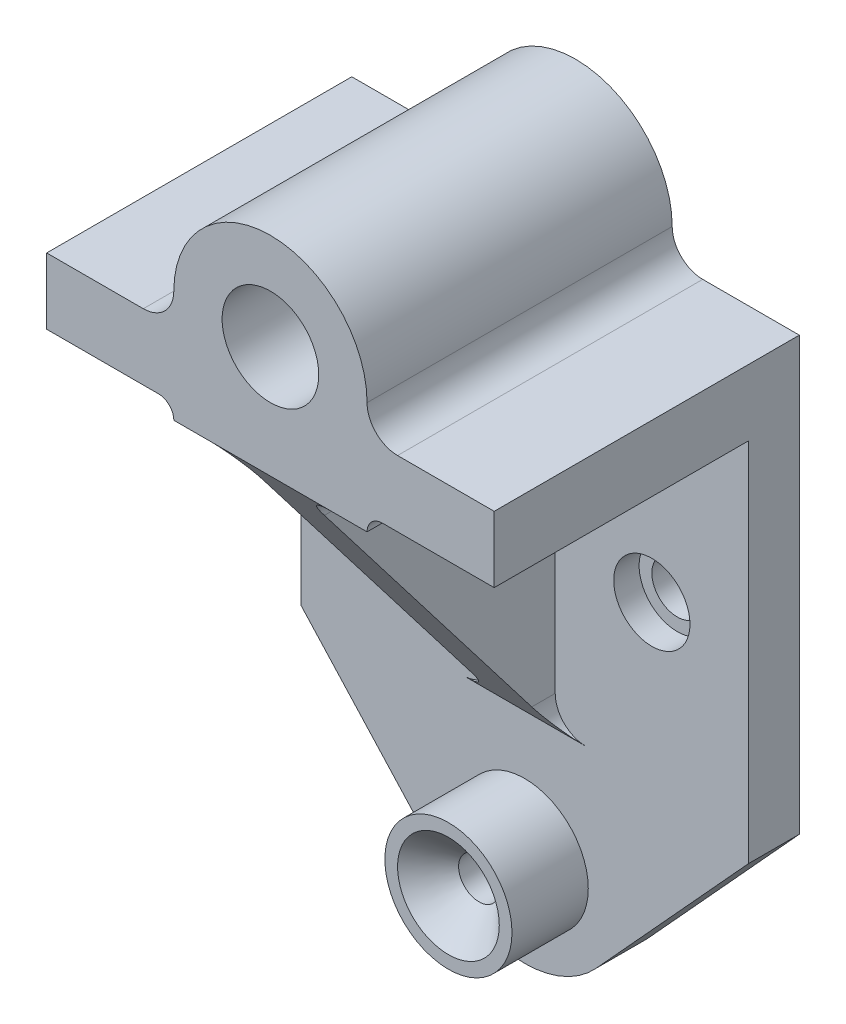
from build123d import *

# Parameters (mm, degrees)
BOSS_EXTRUDE6_DEPTH                          = 60
CUT_EXTRUDE3_DEPTH                           = 150.786514747
CUT_EXTRUDE3_DEPTH_BACK                      = 50
BOSS_EXTRUDE9_DEPTH                          = 50
CUT_EXTRUDE7_DEPTH                           = 25
CBORE_FOR_M8_HEX_HEAD_CAP_SCREW3_D           = 10
CBORE_FOR_M8_HEX_HEAD_CAP_SCREW3_DEPTH       = 10
CBORE_FOR_M8_HEX_HEAD_CAP_SCREW3_CBORE_D     = 15
CBORE_FOR_M8_HEX_HEAD_CAP_SCREW3_CBORE_DEPTH = 5
CBORE_FOR_M8_HEX_HEAD_CAP_SCREW3_TIP         = 3.004303095
CUT_EXTRUDE8_DEPTH                           = 60
SKETCH29_R                                   = 12.5
BOSS_EXTRUDE10_DEPTH                         = 15
BOSS_EXTRUDE11_START                         = -15
SKETCH2_10_R                                 = 12.5
BOSS_EXTRUDE11_DEPTH                         = 15
BOSS_EXTRUDE8_DEPTH                          = 50
CUT_EXTRUDE5_DEPTH                           = 25


with BuildPart() as part:
    # Sketch2 → Boss-Extrude6 (new body)
    with BuildSketch(Plane.XY):
        with BuildLine():
            Line((44, 20), (14.028925254, -12.813635558))
            ThreePointArc((14.028925254, -12.813635558), (0, -19), (-14.028925254, -12.813635558))
            Line((-14.028925254, -12.813635558), (-44, 20))
            Line((-44, 20), (-44, 105))
            Line((-44, 105), (-25, 105))
            ThreePointArc((-25, 105), (-20.757359313, 106.757359313), (-19, 111))
            ThreePointArc((-19, 111), (0, 130), (19, 111))
            ThreePointArc((19, 111), (20.757359313, 106.757359313), (25, 105))
            Line((25, 105), (44, 105))
            Line((44, 105), (44, 20))
        make_face()
    extrude(amount=BOSS_EXTRUDE6_DEPTH)

    # Sketch5 → Cut-Extrude3 (cut, two sides: drawn at the far end of the back side and taken through both)
    with BuildSketch(Plane.XY.offset(60).offset(-CUT_EXTRUDE3_DEPTH_BACK)):
        with BuildLine():
            Line((14.028925254, -12.813635558), (44, 20))
            Line((44, 20), (44, 92))
            Line((44, 92), (22, 92))
            ThreePointArc((22, 92), (19.878679656, 91.121320344), (19, 89))
            Line((19, 89), (-19, 89))
            ThreePointArc((-19, 89), (-19.878679656, 91.121320344), (-22, 92))
            Line((-22, 92), (-44, 92))
            Line((-44, 92), (-44, 20))
            Line((-44, 20), (-14.028925254, -12.813635558))
            ThreePointArc((-14.028925254, -12.813635558), (0, -19), (14.028925254, -12.813635558))
        make_face()
    extrude(amount=CUT_EXTRUDE3_DEPTH + CUT_EXTRUDE3_DEPTH_BACK, mode=Mode.SUBTRACT)

    # Sketch5_11 → Boss-Extrude9 (add)
    with BuildSketch(Plane.XY.offset(60)):
        with BuildLine():
            ThreePointArc((6, 83), (7.757359313, 87.242640687), (12, 89))
            Line((12, 89), (-12, 89))
            ThreePointArc((-12, 89), (-7.757359313, 87.242640687), (-6, 83))
            Line((-6, 83), (-6, 30))
            ThreePointArc((-6, 30), (-7.757359313, 25.757359313), (-12, 24))
            Line((-12, 24), (-9.5, 24))
            Line((-9.5, 24), (9.5, 24))
            Line((9.5, 24), (12, 24))
            ThreePointArc((12, 24), (7.757359313, 25.757359313), (6, 30))
            Line((6, 30), (6, 83))
        make_face()
    extrude(amount=-BOSS_EXTRUDE9_DEPTH)

    # Sketch25 → Cut-Extrude7 (cut, symmetric)
    with BuildSketch(Plane(origin=(6, 0, 0), x_dir=(0, 0, -1), z_dir=(1, 0, 0))):
        Polygon((-60, 89), (-10, 24), (-60, 24), (-60, 30), (-60, 83), align=None)
    extrude(amount=CUT_EXTRUDE7_DEPTH, both=True, mode=Mode.SUBTRACT)

    # CBORE for M8 Hex Head Cap Screw3
    with Locations(Plane(origin=(-25, 55, 10), x_dir=(1, 0, 0), z_dir=(0, 0, 1))):
        with Locations((0, 0), (50, 0)):
            CounterBoreHole(CBORE_FOR_M8_HEX_HEAD_CAP_SCREW3_D / 2, CBORE_FOR_M8_HEX_HEAD_CAP_SCREW3_CBORE_D / 2, CBORE_FOR_M8_HEX_HEAD_CAP_SCREW3_CBORE_DEPTH, depth=CBORE_FOR_M8_HEX_HEAD_CAP_SCREW3_DEPTH)
            with Locations((0, 0, -(CBORE_FOR_M8_HEX_HEAD_CAP_SCREW3_DEPTH + CBORE_FOR_M8_HEX_HEAD_CAP_SCREW3_TIP / 2))):  # 118° drill point
                Cone(0, CBORE_FOR_M8_HEX_HEAD_CAP_SCREW3_D / 2, CBORE_FOR_M8_HEX_HEAD_CAP_SCREW3_TIP, mode=Mode.SUBTRACT)

    # Sketch28 → Cut-Extrude8 (cut)
    with BuildSketch(Plane.XY.offset(60)):
        with BuildLine():
            ThreePointArc((0, 101.5), (9.5, 111), (0, 120.5))
            ThreePointArc((0, 120.5), (-9.5, 111), (0, 101.5))
        make_face()
    extrude(amount=-CUT_EXTRUDE8_DEPTH, mode=Mode.SUBTRACT)

    # Sketch29 → Boss-Extrude10 (add)
    with BuildSketch(Plane.XY.offset(10)):
        Circle(SKETCH29_R)
    extrude(amount=BOSS_EXTRUDE10_DEPTH)

    # Sketch2_10 → Boss-Extrude11 (add)
    with BuildSketch(Plane.XY.offset(BOSS_EXTRUDE11_START)):
        Circle(SKETCH2_10_R)
    extrude(amount=BOSS_EXTRUDE11_DEPTH)

    # Sketch5_9 → Boss-Extrude8 (add)
    with BuildSketch(Plane.XY.offset(60)):
        with BuildLine():
            ThreePointArc((6, 83), (7.757359313, 87.242640687), (12, 89))
            Line((12, 89), (-12, 89))
            ThreePointArc((-12, 89), (-7.757359313, 87.242640687), (-6, 83))
            Line((-6, 83), (-6, 30))
            ThreePointArc((-6, 30), (-7.757359313, 25.757359313), (-12, 24))
            Line((-12, 24), (-9.5, 24))
            Line((-9.5, 24), (9.5, 24))
            Line((9.5, 24), (12, 24))
            ThreePointArc((12, 24), (7.757359313, 25.757359313), (6, 30))
            Line((6, 30), (6, 83))
        make_face()
    extrude(amount=-BOSS_EXTRUDE8_DEPTH)

    # Sketch11 → Cut-Extrude5 (cut, symmetric)
    with BuildSketch(Plane(origin=(6, 0, 0), x_dir=(0, 0, -1), z_dir=(1, 0, 0))):
        Polygon((-60, 24), (-10, 24), (-60, 89), (-60, 83), (-60, 30), align=None)
    extrude(amount=CUT_EXTRUDE5_DEPTH, both=True, mode=Mode.SUBTRACT)

    # Sketch34 → CSK for M8 Flat Head Machine Screw2 (revolve, cut)
    with BuildSketch(Plane(origin=(0, 0, 25), x_dir=(0, -1, 0), z_dir=(1, 0, 0))):
        Polygon((0, 0), (0, 42.403442476), (4, 40), (4, 6), (10, 0), align=None)
    revolve(axis=Axis((0, 0, 31.35), (0, 0, -1)), mode=Mode.SUBTRACT)


solid = part.part
